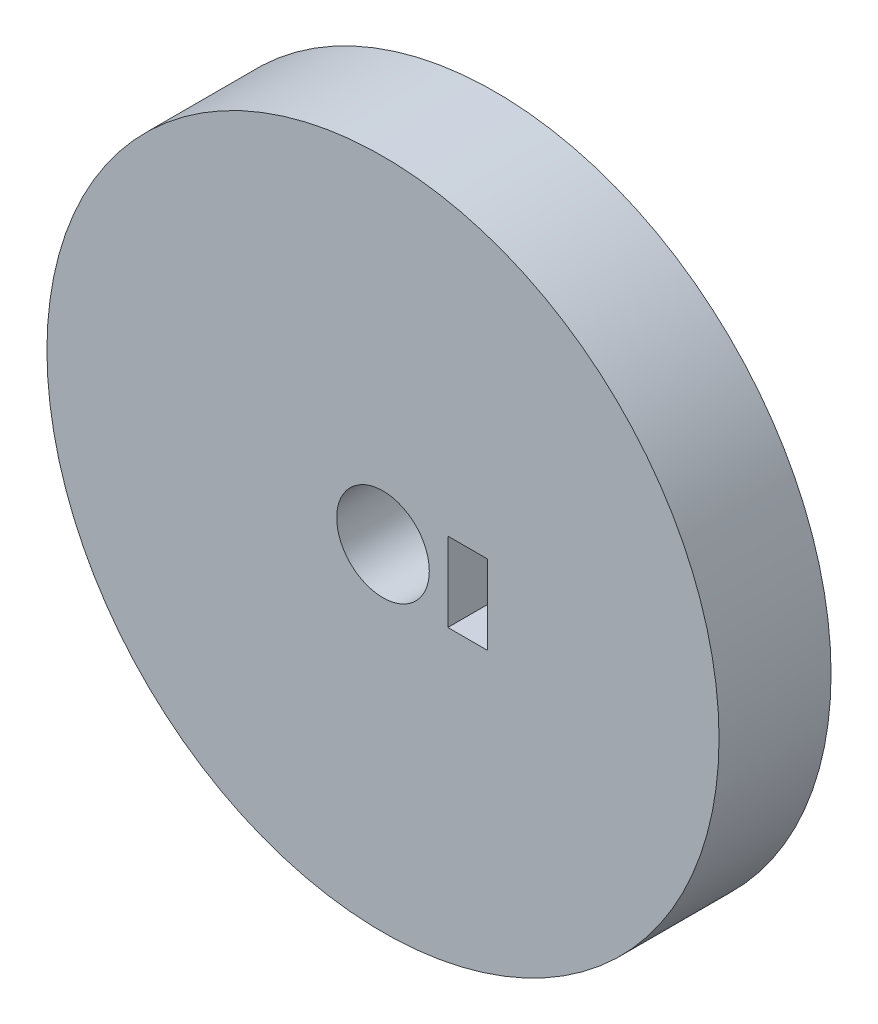
from build123d import *

# Parameters (mm, degrees)
SKETCH1_R           = 45
SKETCH1_R_2         = 6.2
SKETCH1_W           = 5.3
SKETCH1_H           = 10.6
BOSS_EXTRUDE1_DEPTH = 15


with BuildPart() as part:
    # Sketch1 → Boss-Extrude1 (new body)
    with BuildSketch(Plane.XY):
        with Locations((-85.316632571, -12.372200494)):
            Circle(SKETCH1_R)
        with Locations((-85.316632571, -12.372200494)):
            Circle(SKETCH1_R_2, mode=Mode.SUBTRACT)
        with Locations((-73.984503587, -12.372200494)):
            Rectangle(SKETCH1_W, SKETCH1_H, mode=Mode.SUBTRACT)
    extrude(amount=BOSS_EXTRUDE1_DEPTH)


solid = part.part
